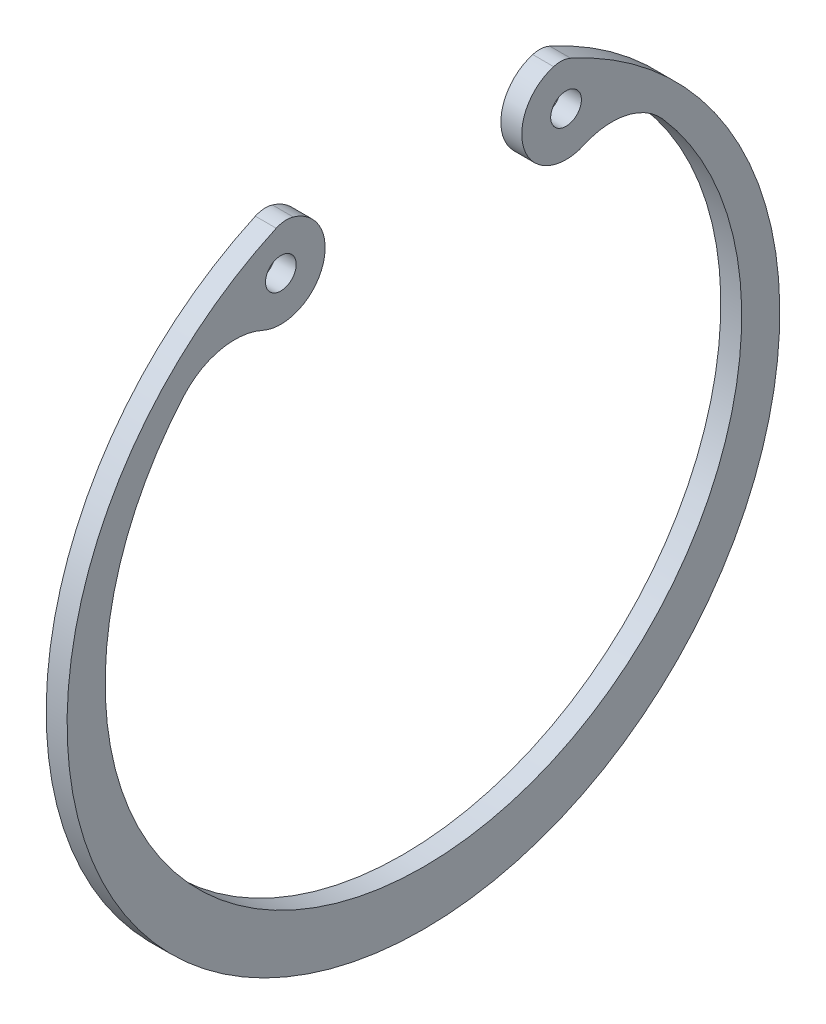
from build123d import *

# Parameters (mm, degrees)
SKETCH_1_R      = 1.25
EXTRUDE_1_DEPTH = 1.7


with BuildPart() as part:
    # Эскиз1 → Бобышка-Вытянуть1 (new body)
    with BuildSketch(Plane(origin=(0, 0, 0), x_dir=(0, 0, -1), z_dir=(1, 0, 0))):
        with BuildLine():
            ThreePointArc((-11.981496808, 26.409160044), (0, -29), (11.981496808, 26.409160044))
            ThreePointArc((11.981496808, 26.409160044), (11.297294852, 26.58278359), (10.595390573, 26.507898118))
            ThreePointArc((10.595390573, 26.507898118), (8.222673438, 21.800549137), (13.083762294, 19.761251179))
            ThreePointArc((13.083762294, 19.761251179), (16.509970242, 20.120507878), (19.47778158, 18.371204548))
            ThreePointArc((19.47778158, 18.371204548), (0, -24.6), (-19.47778158, 18.371204548))
            ThreePointArc((-19.47778158, 18.371204548), (-16.509970242, 20.120507878), (-13.083762294, 19.761251179))
            ThreePointArc((-13.083762294, 19.761251179), (-8.222673438, 21.800549137), (-10.595390573, 26.507898118))
            ThreePointArc((-10.595390573, 26.507898118), (-11.297294852, 26.58278359), (-11.981496808, 26.409160044))
        make_face()
        with Locations((11.604198811, 23.047760113)):
            Circle(SKETCH_1_R, mode=Mode.SUBTRACT)
        with Locations((-11.604198811, 23.047760113)):
            Circle(SKETCH_1_R, mode=Mode.SUBTRACT)
    extrude(amount=EXTRUDE_1_DEPTH)


solid = part.part
